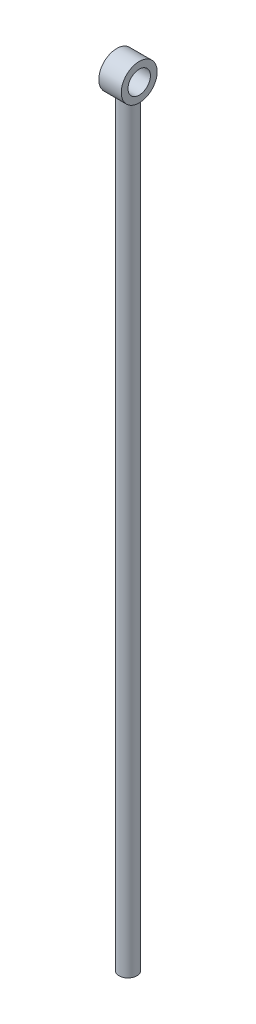
from build123d import *

# Parameters (mm, degrees)
SKETCH1_R           = 5.08
SKETCH1_R_2         = 3.175
BOSS_EXTRUDE1_DEPTH = 3.175
SKETCH2_R           = 2.54
BOSS_EXTRUDE2_DEPTH = 215.9


with BuildPart() as part:
    # Sketch1 → Boss-Extrude1 (new body, symmetric)
    with BuildSketch(Plane(origin=(0, 0, 0), x_dir=(0, 0, -1), z_dir=(1, 0, 0))):
        Circle(SKETCH1_R)
        Circle(SKETCH1_R_2, mode=Mode.SUBTRACT)
    extrude(amount=BOSS_EXTRUDE1_DEPTH, both=True)

    # Sketch2 → Boss-Extrude2 (add)
    with BuildSketch(Plane(origin=(0, -3.302, 0), x_dir=(1, 0, 0), z_dir=(0, 1, 0))):
        Circle(SKETCH2_R)
    extrude(amount=-BOSS_EXTRUDE2_DEPTH)


solid = part.part
